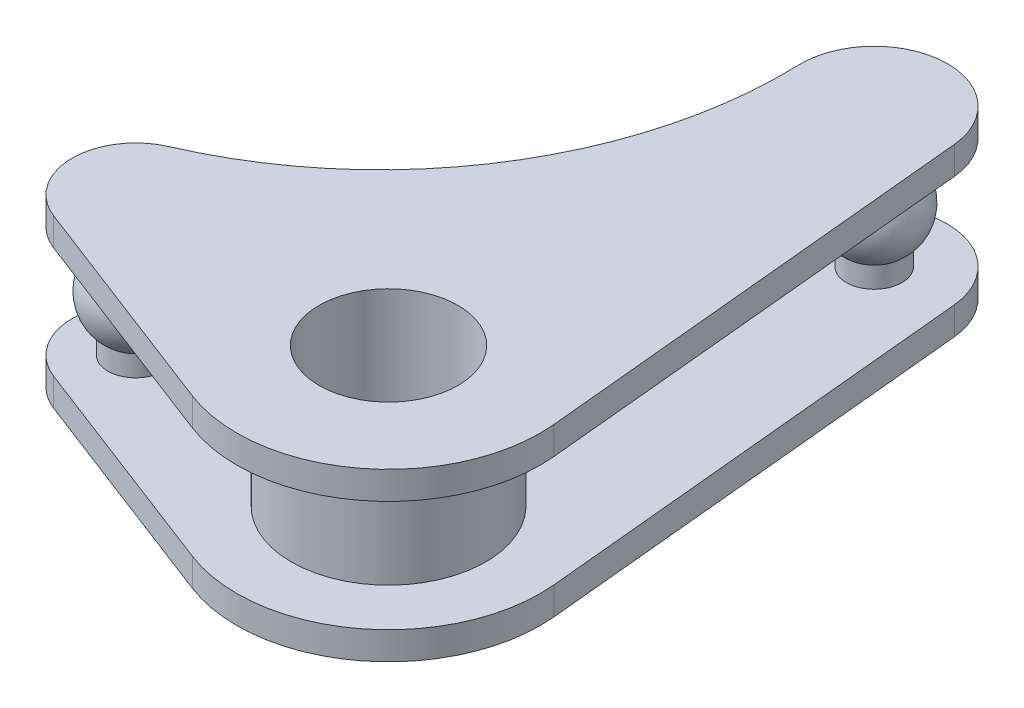
from build123d import *

# Parameters (mm, degrees)
SKETCH1_R           = 2.5
SKETCH1_R_2         = 0.0005
BOSS_EXTRUDE1_DEPTH = 6
SHELL2_T            = -1


with BuildPart() as part:
    # Sketch1 → Boss-Extrude1 (new body)
    with BuildSketch(Plane(origin=(0, 0, 0), x_dir=(1, 0, 0), z_dir=(0, 1, 0))):
        with BuildLine():
            Line((3.916781356, 16.448937177), (5.439290459, 0.519891097))
            ThreePointArc((5.439290459, 0.519891097), (3.305372063, -4.350940471), (-1.959267, -5.100729386))
            Line((-1.959267, -5.100729386), (-10.066731285, -1.986530215))
            ThreePointArc((-10.066731285, -1.986530215), (-11.531799407, 0.09893627), (-10.154571379, 2.243426424))
            ThreePointArc((-10.154571379, 2.243426424), (-3.622328357, 7.82371847), (-1.360395605, 16.11187378))
            ThreePointArc((-1.360395605, 16.11187378), (1.114889004, 18.837145351), (3.916781356, 16.448937177))
        make_face()
        Circle(SKETCH1_R, mode=Mode.SUBTRACT)
        with Locations((-9.247450838, 0.146373492)):
            Circle(SKETCH1_R_2, mode=Mode.SUBTRACT)
        with Locations((1.283504381, 16.197246766)):
            Circle(SKETCH1_R_2, mode=Mode.SUBTRACT)
    extrude(amount=BOSS_EXTRUDE1_DEPTH)

    # Shell2
    shell2_openings = [part.faces().sort_by_distance(p)[0] for p in [
        (-4.689905925, 3, -8.500684286),
        (1.19654094, 3, -17.558775415),
        (4.678035907, 3, -8.484414137),
        (2.522691896, 3, 3.320679808),
        (-6.012999142, 3, 3.543629801),
        (-10.821225369, 3, -0.113692187),
    ]]
    offset(amount=SHELL2_T, openings=shell2_openings, kind=Kind.INTERSECTION)

    # Sketch6 → Revolve4 (revolve)
    with BuildSketch(Plane(origin=(0, 0, 0), x_dir=(0.078994505, 0, -0.996875051), z_dir=(0.996875051, 0, 0.078994505))):
        with BuildLine():
            Line((16.248404329, 4.599999994), (16.248137663, 1.400000006))
            ThreePointArc((16.248137663, 1.400000006), (14.648271001, 3.000133333), (16.248404329, 4.599999994))
        make_face()
    revolve(axis=Axis((1.283504381, 0, -16.197246766), (6.583e-06, 0.999999997, -8.3073e-05)))

    # Sketch5 → Revolve-Thin1 (revolve)
    with BuildSketch(Plane(origin=(0, 0, 0), x_dir=(0.999874752, 0, 0.015826541), z_dir=(-0.015826541, 0, 0.999874752))):
        with BuildLine():
            ThreePointArc((-9.248992537, 4.599999994), (-10.848859203, 3.000050396), (-9.249093329, 1.400000017))
            Line((-9.249093329, 1.400000017), (-9.248947001, 2.400000006))
            ThreePointArc((-9.248947001, 2.400000006), (-9.848859204, 3.000018899), (-9.248909204, 3.599999998))
            Line((-9.248909204, 3.599999998), (-9.248992537, 4.599999994))
        make_face()
    revolve(axis=Axis((-9.247450838, 0, -0.146373492), (-8.3323e-05, 0.999999997, -1.319e-06)))


solid = part.part
